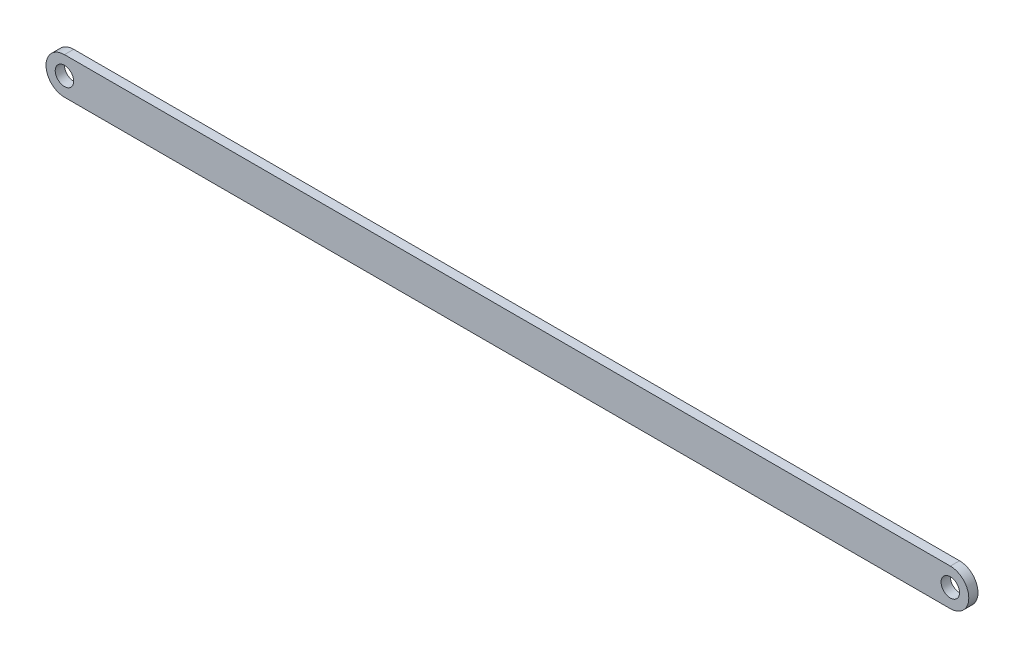
from build123d import *

# Parameters (mm, degrees)
SKETCH1_R           = 3.175
BOSS_EXTRUDE2_DEPTH = 3.175


with BuildPart() as part:
    # Sketch1 → Boss-Extrude2 (new body)
    with BuildSketch(Plane.XY):
        with BuildLine():
            Line((-152.4, 6.35), (152.4, 6.35))
            ThreePointArc((152.4, 6.35), (158.75, 0), (152.4, -6.35))
            Line((152.4, -6.35), (-152.4, -6.35))
            ThreePointArc((-152.4, -6.35), (-158.75, 0), (-152.4, 6.35))
        make_face()
        with Locations((-152.4, 0)):
            Circle(SKETCH1_R, mode=Mode.SUBTRACT)
        with Locations((152.4, 0)):
            Circle(SKETCH1_R, mode=Mode.SUBTRACT)
    extrude(amount=BOSS_EXTRUDE2_DEPTH)


solid = part.part
